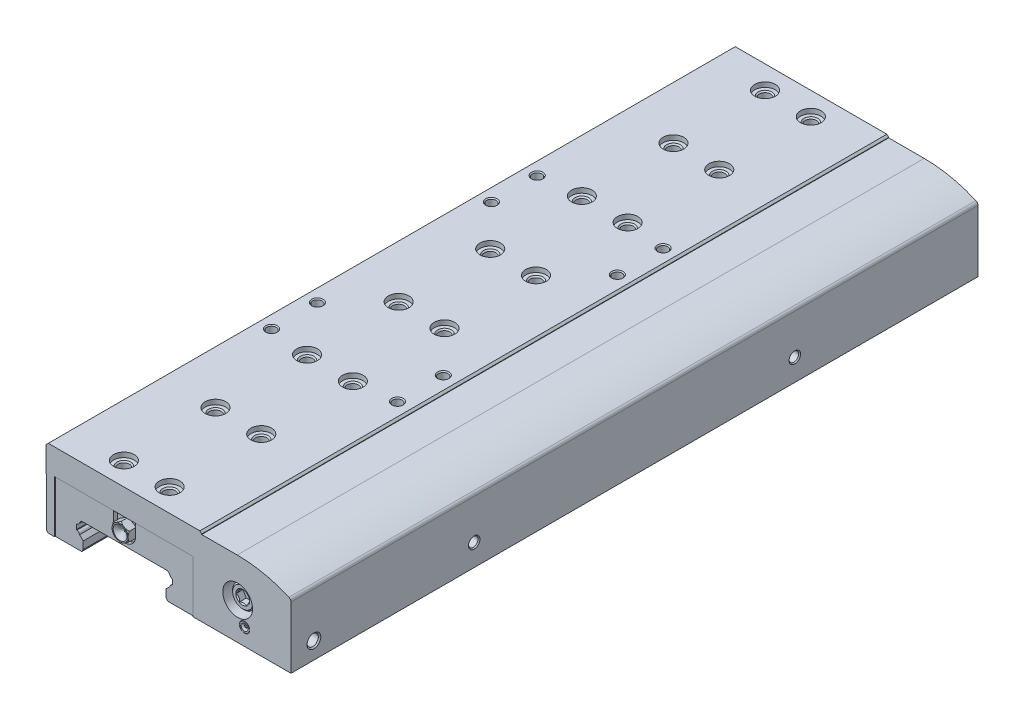
from build123d import *

# Parameters (mm, degrees)
BOSS_EXTRUDE1_DEPTH      = 300
SKETCH2_W                = 115
SKETCH2_H                = 45
CUT_EXTRUDE1_DEPTH       = 300
BOSS_EXTRUDE2_DEPTH      = 150
BOSS_EXTRUDE2_DEPTH_BACK = 150
BOSS_EXTRUDE3_DEPTH      = 150
BOSS_EXTRUDE3_DEPTH_BACK = 150
SKETCH4_W                = 60.6
SKETCH4_H                = 22.8
CUT_EXTRUDE2_DEPTH       = 3
CUT_EXTRUDE3_DEPTH       = 3
SKETCH9_W                = 1
SKETCH9_H                = 2.25
SKETCH40_W               = 2.1
SKETCH40_H               = 3.5
SKETCH41_W               = 2.1
SKETCH41_H               = 3.5
CUT_EXTRUDE4_DEPTH       = 170
CUT_EXTRUDE4_DEPTH_BACK  = 170
SKETCH43_W               = 60.6
SKETCH43_H               = 22.8
CUT_EXTRUDE5_DEPTH       = 0.35
CUT_EXTRUDE6_DEPTH       = 0.35
CUT_EXTRUDE6_DEPTH_BACK  = 0.35
SKETCH44_W               = 60.6
SKETCH44_H               = 22.8
CUT_EXTRUDE7_DEPTH       = 1.95
CUT_EXTRUDE8_START       = 1.95
CUT_EXTRUDE8_DEPTH       = 1.95
CUT_EXTRUDE9_DEPTH       = 1.95
CUT_EXTRUDE9_DEPTH_BACK  = 1.95
SKETCH49_R               = 4.7
CUT_EXTRUDE10_DEPTH      = 1.95
CUT_EXTRUDE10_DEPTH_BACK = 1.95
SKETCH50_R               = 4.7


with BuildPart() as part:
    # Sketch1 → Boss-Extrude1 (new body)
    with BuildSketch(Plane.XY):
        with BuildLine():
            Line((0, 34), (0, 22))
            Line((0, 22), (0.2, 22))
            Line((0.2, 22), (0.2, 0))
            Line((0.2, 0), (3.7, 0))
            Line((3.7, 0), (3.7, 22.8))
            Line((3.7, 22.8), (64.3, 22.8))
            Line((64.3, 22.8), (64.3, 0))
            Line((64.3, 0), (107, 0))
            Line((107, 0), (107, 27.930241671))
            ThreePointArc((107, 27.930241671), (95.52032081, 31.718146843), (83.5, 33))
            Line((83.5, 33), (68, 33))
            Line((68, 33), (68, 34))
            Line((68, 34), (0, 34))
        make_face()
    extrude(amount=-BOSS_EXTRUDE1_DEPTH)

    # Sketch2 → Cut-Extrude1 (cut)
    with BuildSketch(Plane.XY):
        with Locations((55.5, 20.5)):
            Rectangle(SKETCH2_W, SKETCH2_H)
        with BuildLine():
            Line((0, 33), (0, 22))
            Line((0, 22), (0.2, 22))
            Line((0.2, 22), (0.2, 1.2))
            ThreePointArc((0.2, 1.2), (0.551471863, 0.351471863), (1.4, 0))
            Line((1.4, 0), (107, 0))
            Line((107, 0), (107, 26.953410092))
            ThreePointArc((107, 26.953410092), (106.753373869, 27.777457387), (106.094594741, 28.330529221))
            ThreePointArc((106.094594741, 28.330529221), (95.036026925, 31.82042711), (83.5, 33))
            Line((83.5, 33), (68, 33))
            Line((68, 33), (68, 33.2))
            Line((68, 33.2), (67.2, 34))
            Line((67.2, 34), (1, 34))
            Line((1, 34), (0, 33))
        make_face(mode=Mode.SUBTRACT)
    extrude(amount=-CUT_EXTRUDE1_DEPTH, mode=Mode.SUBTRACT)

    # Sketch3 → Boss-Extrude2 (add, two sides: drawn at the far end of the back side and taken through both)
    with BuildSketch(Plane.XY.offset(-150).offset(-BOSS_EXTRUDE2_DEPTH_BACK)):
        Polygon((3.7, 0), (13, 0), (13, 11.5), (55, 11.5), (55, 0), (64.3, 0), (64.3, 22.8), (3.7, 22.8), align=None)
    extrude(amount=BOSS_EXTRUDE2_DEPTH + BOSS_EXTRUDE2_DEPTH_BACK)

    # Sketch4 → Boss-Extrude3 (add, two sides: drawn at the far end of the back side and taken through both)
    with BuildSketch(Plane.XY.offset(-150).offset(-BOSS_EXTRUDE3_DEPTH_BACK)):
        with Locations((34, 11.4)):
            Rectangle(SKETCH4_W, SKETCH4_H)
    extrude(amount=BOSS_EXTRUDE3_DEPTH + BOSS_EXTRUDE3_DEPTH_BACK)

    # Sketch5 → Cut-Revolve1 (revolve, cut)
    with BuildSketch(Plane(origin=(83.7, 0, 0), x_dir=(0, 0, -1), z_dir=(1, 0, 0))):
        Polygon((299.95, 16), (299.95, 19.55), (299.25, 20.25), (300, 21), (300, 16), align=None)
    revolve(axis=Axis((83.7, 16, -300), (0, 0, 1)), mode=Mode.SUBTRACT)

    # Sketch6 → Cut-Extrude2 (cut)
    with BuildSketch(Plane(origin=(0, 0, -299.95), x_dir=(-1, 0, 0), z_dir=(0, 0, -1))):
        Polygon((-84.854700538, 14), (-82.545299462, 14), (-81.390598923, 16), (-82.545299462, 18), (-84.854700538, 18), (-86.009401077, 16), align=None)
    extrude(amount=-CUT_EXTRUDE2_DEPTH, mode=Mode.SUBTRACT)

    # Sketch7 → Cut-Revolve2 (revolve, cut)
    with BuildSketch(Plane(origin=(83.7, 0, 0), x_dir=(0, 0, -1), z_dir=(1, 0, 0))):
        Polygon((0, 16), (0, 22.5), (8.2, 22.5), (8.2, 21), (2.8, 21), (2.2, 20.4), (2.2, 19), (5.2, 16), align=None)
    revolve(axis=Axis((83.7, 16, -5.2), (0, 0, 1)), mode=Mode.SUBTRACT)

    # Sketch8 → Cut-Extrude3 (cut)
    with BuildSketch(Plane.XY.offset(-2.2)):
        Polygon((82.256624327, 13.5), (85.143375673, 13.5), (86.586751346, 16), (85.143375673, 18.5), (82.256624327, 18.5), (80.813248654, 16), align=None)
    extrude(amount=-CUT_EXTRUDE3_DEPTH, mode=Mode.SUBTRACT)

    # Sketch9 → Cut-Revolve3 (revolve, cut)
    with BuildSketch(Plane(origin=(86.7, 0, 0), x_dir=(0, 0, -1), z_dir=(1, 0, 0))):
        with Locations((0.5, 8.425)):
            Rectangle(SKETCH9_W, SKETCH9_H)
    revolve(axis=Axis((86.7, 7.3, -1), (0, 0, 1)), mode=Mode.SUBTRACT)

    # Sketch10 → Revolve1 (revolve)
    with BuildSketch(Plane(origin=(86.7, 0, 0), x_dir=(0, 0, -1), z_dir=(1, 0, 0))):
        with BuildLine():
            Line((0.8, 7.85), (0.548482756, 7.85))
            Line((0.548482756, 7.85), (0, 8.8))
            Line((0, 8.8), (0, 9.4))
            Line((0, 9.4), (1, 9.4))
            Line((1, 9.4), (1, 7.3))
            Line((1, 7.3), (0.533012702, 7.3))
            ThreePointArc((0.533012702, 7.3), (0.603287011, 7.605688656), (0.8, 7.85))
        make_face()
    revolve(axis=Axis((86.7, 7.3, -1), (0, 0, 1)))

    # Sketch11 → Cut-Revolve4 (revolve, cut)
    with BuildSketch(Plane(origin=(0, 9.5, 0), x_dir=(1, 0, 0), z_dir=(0, 1, 0))):
        Polygon((107, 80), (107, 77.5), (106.567, 77.933), (97, 77.933), (95.806616994, 80), align=None)
    revolve(axis=Axis((95.806616994, 9.5, -80), (1, 0, 0)), mode=Mode.SUBTRACT)

    # Sketch12 → Cut-Revolve5 (revolve, cut)
    with BuildSketch(Plane(origin=(0, 9.5, 0), x_dir=(1, 0, 0), z_dir=(0, 1, 0))):
        Polygon((107, 220), (107, 217.5), (106.567, 217.933), (97, 217.933), (95.806616994, 220), align=None)
    revolve(axis=Axis((95.806616994, 9.5, -220), (1, 0, 0)), mode=Mode.SUBTRACT)

    # Sketch13 → Cut-Revolve6 (revolve, cut)
    with BuildSketch(Plane.XY.offset(-10)):
        Polygon((99, 7.3), (99, 9.7585), (106.4585, 9.7585), (107, 10.3), (107, 7.3), align=None)
    revolve(axis=Axis((107, 7.3, -10), (-1, 0, 0)), mode=Mode.SUBTRACT)

    # Sketch14 → Cut-Revolve7 (revolve, cut)
    with BuildSketch(Plane(origin=(6.5, 0, 0), x_dir=(0, 0, -1), z_dir=(1, 0, 0))):
        Polygon((92, 34), (94.5, 34), (94.067, 33.567), (94.067, 26.5), (92, 26.5), align=None)
    revolve(axis=Axis((6.5, 26.5, -92), (0, 1, 0)), mode=Mode.SUBTRACT)

    # Sketch15 → Cut-Revolve8 (revolve, cut)
    with BuildSketch(Plane(origin=(61.5, 0, 0), x_dir=(0, 0, -1), z_dir=(1, 0, 0))):
        Polygon((92, 34), (94.5, 34), (94.067, 33.567), (94.067, 26.5), (92, 26.5), align=None)
    revolve(axis=Axis((61.5, 26.5, -92), (0, 1, 0)), mode=Mode.SUBTRACT)

    # Sketch16 → Cut-Revolve9 (revolve, cut)
    with BuildSketch(Plane(origin=(61.5, 0, 0), x_dir=(0, 0, -1), z_dir=(1, 0, 0))):
        Polygon((112, 34), (114.5, 34), (114.067, 33.567), (114.067, 26.5), (112, 26.5), align=None)
    revolve(axis=Axis((61.5, 26.5, -112), (0, 1, 0)), mode=Mode.SUBTRACT)

    # Sketch17 → Cut-Revolve10 (revolve, cut)
    with BuildSketch(Plane(origin=(6.5, 0, 0), x_dir=(0, 0, -1), z_dir=(1, 0, 0))):
        Polygon((112, 34), (114.5, 34), (114.067, 33.567), (114.067, 26.5), (112, 26.5), align=None)
    revolve(axis=Axis((6.5, 26.5, -112), (0, 1, 0)), mode=Mode.SUBTRACT)

    # Sketch18 → Cut-Revolve11 (revolve, cut)
    with BuildSketch(Plane(origin=(61.5, 0, 0), x_dir=(0, 0, -1), z_dir=(1, 0, 0))):
        Polygon((188, 34), (190.5, 34), (190.067, 33.567), (190.067, 26.5), (188, 26.5), align=None)
    revolve(axis=Axis((61.5, 26.5, -188), (0, 1, 0)), mode=Mode.SUBTRACT)

    # Sketch19 → Cut-Revolve12 (revolve, cut)
    with BuildSketch(Plane(origin=(6.5, 0, 0), x_dir=(0, 0, -1), z_dir=(1, 0, 0))):
        Polygon((188, 34), (190.5, 34), (190.067, 33.567), (190.067, 26.5), (188, 26.5), align=None)
    revolve(axis=Axis((6.5, 26.5, -188), (0, 1, 0)), mode=Mode.SUBTRACT)

    # Sketch20 → Cut-Revolve13 (revolve, cut)
    with BuildSketch(Plane(origin=(61.5, 0, 0), x_dir=(0, 0, -1), z_dir=(1, 0, 0))):
        Polygon((208, 34), (210.5, 34), (210.067, 33.567), (210.067, 26.5), (208, 26.5), align=None)
    revolve(axis=Axis((61.5, 26.5, -208), (0, 1, 0)), mode=Mode.SUBTRACT)

    # Sketch21 → Cut-Revolve14 (revolve, cut)
    with BuildSketch(Plane(origin=(6.5, 0, 0), x_dir=(0, 0, -1), z_dir=(1, 0, 0))):
        Polygon((208, 34), (210.5, 34), (210.067, 33.567), (210.067, 26.5), (208, 26.5), align=None)
    revolve(axis=Axis((6.5, 26.5, -208), (0, 1, 0)), mode=Mode.SUBTRACT)

    # Sketch22 → Cut-Revolve15 (revolve, cut)
    with BuildSketch(Plane(origin=(24, 0, 0), x_dir=(0, 0, -1), z_dir=(1, 0, 0))):
        Polygon((10, 25.4), (7.5415, 25.4), (7.5415, 31.3585), (7, 31.9), (5.5, 31.9), (5.5, 34), (10, 34), align=None)
    revolve(axis=Axis((24, 31.9, -10), (0, -1, 0)), mode=Mode.SUBTRACT)

    # Sketch23 → Cut-Revolve16 (revolve, cut)
    with BuildSketch(Plane(origin=(24, 0, 0), x_dir=(0, 0, -1), z_dir=(1, 0, 0))):
        Polygon((50, 25.4), (47.5415, 25.4), (47.5415, 31.3585), (47, 31.9), (45.5, 31.9), (45.5, 34), (50, 34), align=None)
    revolve(axis=Axis((24, 31.9, -50), (0, -1, 0)), mode=Mode.SUBTRACT)

    # Sketch24 → Cut-Revolve17 (revolve, cut)
    with BuildSketch(Plane(origin=(24, 0, 0), x_dir=(0, 0, -1), z_dir=(1, 0, 0))):
        Polygon((90, 25.4), (87.5415, 25.4), (87.5415, 31.3585), (87, 31.9), (85.5, 31.9), (85.5, 34), (90, 34), align=None)
    revolve(axis=Axis((24, 31.9, -90), (0, -1, 0)), mode=Mode.SUBTRACT)

    # Sketch25 → Cut-Revolve18 (revolve, cut)
    with BuildSketch(Plane(origin=(24, 0, 0), x_dir=(0, 0, -1), z_dir=(1, 0, 0))):
        Polygon((130, 25.4), (127.5415, 25.4), (127.5415, 31.3585), (127, 31.9), (125.5, 31.9), (125.5, 34), (130, 34), align=None)
    revolve(axis=Axis((24, 31.9, -130), (0, -1, 0)), mode=Mode.SUBTRACT)

    # Sketch26 → Cut-Revolve19 (revolve, cut)
    with BuildSketch(Plane(origin=(24, 0, 0), x_dir=(0, 0, -1), z_dir=(1, 0, 0))):
        Polygon((170, 25.4), (167.5415, 25.4), (167.5415, 31.3585), (167, 31.9), (165.5, 31.9), (165.5, 34), (170, 34), align=None)
    revolve(axis=Axis((24, 31.9, -170), (0, -1, 0)), mode=Mode.SUBTRACT)

    # Sketch27 → Cut-Revolve20 (revolve, cut)
    with BuildSketch(Plane(origin=(24, 0, 0), x_dir=(0, 0, -1), z_dir=(1, 0, 0))):
        Polygon((210, 25.4), (207.5415, 25.4), (207.5415, 31.3585), (207, 31.9), (205.5, 31.9), (205.5, 34), (210, 34), align=None)
    revolve(axis=Axis((24, 31.9, -210), (0, -1, 0)), mode=Mode.SUBTRACT)

    # Sketch28 → Cut-Revolve21 (revolve, cut)
    with BuildSketch(Plane(origin=(24, 0, 0), x_dir=(0, 0, -1), z_dir=(1, 0, 0))):
        Polygon((250, 25.4), (247.5415, 25.4), (247.5415, 31.3585), (247, 31.9), (245.5, 31.9), (245.5, 34), (250, 34), align=None)
    revolve(axis=Axis((24, 31.9, -250), (0, -1, 0)), mode=Mode.SUBTRACT)

    # Sketch29 → Cut-Revolve22 (revolve, cut)
    with BuildSketch(Plane(origin=(24, 0, 0), x_dir=(0, 0, -1), z_dir=(1, 0, 0))):
        Polygon((290, 25.4), (287.5415, 25.4), (287.5415, 31.3585), (287, 31.9), (285.5, 31.9), (285.5, 34), (290, 34), align=None)
    revolve(axis=Axis((24, 31.9, -290), (0, -1, 0)), mode=Mode.SUBTRACT)

    # Sketch30 → Cut-Revolve23 (revolve, cut)
    with BuildSketch(Plane(origin=(44, 0, 0), x_dir=(0, 0, -1), z_dir=(1, 0, 0))):
        Polygon((10, 25.4), (7.5415, 25.4), (7.5415, 31.3585), (7, 31.9), (5.5, 31.9), (5.5, 34), (10, 34), align=None)
    revolve(axis=Axis((44, 31.9, -10), (0, -1, 0)), mode=Mode.SUBTRACT)

    # Sketch31 → Cut-Revolve24 (revolve, cut)
    with BuildSketch(Plane(origin=(44, 0, 0), x_dir=(0, 0, -1), z_dir=(1, 0, 0))):
        Polygon((50, 25.4), (47.5415, 25.4), (47.5415, 31.3585), (47, 31.9), (45.5, 31.9), (45.5, 34), (50, 34), align=None)
    revolve(axis=Axis((44, 31.9, -50), (0, -1, 0)), mode=Mode.SUBTRACT)

    # Sketch32 → Cut-Revolve25 (revolve, cut)
    with BuildSketch(Plane(origin=(44, 0, 0), x_dir=(0, 0, -1), z_dir=(1, 0, 0))):
        Polygon((90, 25.4), (87.5415, 25.4), (87.5415, 31.3585), (87, 31.9), (85.5, 31.9), (85.5, 34), (90, 34), align=None)
    revolve(axis=Axis((44, 31.9, -90), (0, -1, 0)), mode=Mode.SUBTRACT)

    # Sketch33 → Cut-Revolve26 (revolve, cut)
    with BuildSketch(Plane(origin=(44, 0, 0), x_dir=(0, 0, -1), z_dir=(1, 0, 0))):
        Polygon((130, 25.4), (127.5415, 25.4), (127.5415, 31.3585), (127, 31.9), (125.5, 31.9), (125.5, 34), (130, 34), align=None)
    revolve(axis=Axis((44, 31.9, -130), (0, -1, 0)), mode=Mode.SUBTRACT)

    # Sketch34 → Cut-Revolve27 (revolve, cut)
    with BuildSketch(Plane(origin=(44, 0, 0), x_dir=(0, 0, -1), z_dir=(1, 0, 0))):
        Polygon((170, 25.4), (167.5415, 25.4), (167.5415, 31.3585), (167, 31.9), (165.5, 31.9), (165.5, 34), (170, 34), align=None)
    revolve(axis=Axis((44, 31.9, -170), (0, -1, 0)), mode=Mode.SUBTRACT)

    # Sketch35 → Cut-Revolve28 (revolve, cut)
    with BuildSketch(Plane(origin=(44, 0, 0), x_dir=(0, 0, -1), z_dir=(1, 0, 0))):
        Polygon((210, 25.4), (207.5415, 25.4), (207.5415, 31.3585), (207, 31.9), (205.5, 31.9), (205.5, 34), (210, 34), align=None)
    revolve(axis=Axis((44, 31.9, -210), (0, -1, 0)), mode=Mode.SUBTRACT)

    # Sketch36 → Cut-Revolve29 (revolve, cut)
    with BuildSketch(Plane(origin=(44, 0, 0), x_dir=(0, 0, -1), z_dir=(1, 0, 0))):
        Polygon((250, 25.4), (247.5415, 25.4), (247.5415, 31.3585), (247, 31.9), (245.5, 31.9), (245.5, 34), (250, 34), align=None)
    revolve(axis=Axis((44, 31.9, -250), (0, -1, 0)), mode=Mode.SUBTRACT)

    # Sketch37 → Cut-Revolve30 (revolve, cut)
    with BuildSketch(Plane(origin=(44, 0, 0), x_dir=(0, 0, -1), z_dir=(1, 0, 0))):
        Polygon((290, 25.4), (287.5415, 25.4), (287.5415, 31.3585), (287, 31.9), (285.5, 31.9), (285.5, 34), (290, 34), align=None)
    revolve(axis=Axis((44, 31.9, -290), (0, -1, 0)), mode=Mode.SUBTRACT)

    # Sketch38 → Cut-Revolve31 (revolve, cut)
    with BuildSketch(Plane(origin=(0, 27, 0), x_dir=(1, 0, 0), z_dir=(0, 1, 0))):
        Polygon((0, 120), (0, 123), (0.5415, 122.4585), (15, 122.4585), (16.419415637, 120), align=None)
    revolve(axis=Axis((16.419415637, 27, -120), (-1, 0, 0)), mode=Mode.SUBTRACT)

    # Sketch39 → Cut-Revolve32 (revolve, cut)
    with BuildSketch(Plane(origin=(0, 27, 0), x_dir=(1, 0, 0), z_dir=(0, 1, 0))):
        Polygon((0, 180), (0, 183), (0.5415, 182.4585), (15, 182.4585), (16.419415637, 180), align=None)
    revolve(axis=Axis((16.419415637, 27, -180), (-1, 0, 0)), mode=Mode.SUBTRACT)

    # Sketch40 → Cut-Revolve33 (revolve, cut)
    with BuildSketch(Plane(origin=(0, 27, 0), x_dir=(1, 0, 0), z_dir=(0, 1, 0))):
        with Locations((1.05, 206.75)):
            Rectangle(SKETCH40_W, SKETCH40_H)
    revolve(axis=Axis((2.1, 27, -205), (-1, 0, 0)), mode=Mode.SUBTRACT)

    # Sketch41 → Cut-Revolve34 (revolve, cut)
    with BuildSketch(Plane(origin=(0, 27, 0), x_dir=(1, 0, 0), z_dir=(0, 1, 0))):
        with Locations((1.05, 96.75)):
            Rectangle(SKETCH41_W, SKETCH41_H)
    revolve(axis=Axis((2.1, 27, -95), (-1, 0, 0)), mode=Mode.SUBTRACT)

    # Sketch42 → Cut-Extrude4 (cut, two sides: drawn at the far end of the back side and taken through both)
    with BuildSketch(Plane.XY.offset(-150).offset(-CUT_EXTRUDE4_DEPTH_BACK)):
        with BuildLine():
            Line((13, -5), (55, -5))
            Line((55, -5), (55, -3.93))
            Line((55, -3.93), (52.1, 1.092947342))
            Line((52.1, 1.092947342), (52.1, 4.34))
            Line((52.1, 4.34), (53.670892773, 5.910892773))
            ThreePointArc((53.670892773, 5.910892773), (54.063837303, 6.651162697), (54.804107227, 7.044107227))
            Line((54.804107227, 7.044107227), (55, 7.24))
            Line((55, 7.24), (55, 9.25))
            Line((55, 9.25), (54.804107227, 9.445892773))
            ThreePointArc((54.804107227, 9.445892773), (54.063837303, 9.838837303), (53.670892773, 10.579107227))
            Line((53.670892773, 10.579107227), (52.75, 11.5))
            Line((52.75, 11.5), (15.25, 11.5))
            Line((15.25, 11.5), (14.329107227, 10.579107227))
            ThreePointArc((14.329107227, 10.579107227), (13.936162697, 9.838837303), (13.195892773, 9.445892773))
            Line((13.195892773, 9.445892773), (13, 9.25))
            Line((13, 9.25), (13, 7.24))
            Line((13, 7.24), (13.195892773, 7.044107227))
            ThreePointArc((13.195892773, 7.044107227), (13.936162697, 6.651162697), (14.329107227, 5.910892773))
            Line((14.329107227, 5.910892773), (15.9, 4.34))
            Line((15.9, 4.34), (15.9, 1.092947342))
            Line((15.9, 1.092947342), (13, -3.93))
            Line((13, -3.93), (13, -5))
        make_face()
    extrude(amount=CUT_EXTRUDE4_DEPTH + CUT_EXTRUDE4_DEPTH_BACK, mode=Mode.SUBTRACT)

    # Sketch43 → Cut-Extrude5 (cut)
    with BuildSketch(Plane.XY):
        with Locations((34, 11.4)):
            Rectangle(SKETCH43_W, SKETCH43_H)
    extrude(amount=-CUT_EXTRUDE5_DEPTH, mode=Mode.SUBTRACT)

    # Sketch44 → Cut-Extrude6 (cut, two sides: drawn at the far end of the back side and taken through both)
    with BuildSketch(Plane.XY.offset(-300).offset(-CUT_EXTRUDE6_DEPTH_BACK)):
        with Locations((34, 11.4)):
            Rectangle(SKETCH44_W, SKETCH44_H)
    extrude(amount=CUT_EXTRUDE6_DEPTH + CUT_EXTRUDE6_DEPTH_BACK, mode=Mode.SUBTRACT)

    # Sketch45 → Cut-Extrude7 (cut)
    with BuildSketch(Plane.XY):
        with BuildLine():
            Line((29.2, 22.8), (29.2, 17.5))
            ThreePointArc((29.2, 17.5), (34, 12.7), (38.8, 17.5))
            Line((38.8, 17.5), (38.8, 22.8))
            Line((38.8, 22.8), (29.2, 22.8))
        make_face()
    extrude(amount=-CUT_EXTRUDE7_DEPTH, mode=Mode.SUBTRACT)

    # Sketch46 → Cut-Extrude8 (cut)
    with BuildSketch(Plane.XY.offset(-300).offset(CUT_EXTRUDE8_START)):
        with BuildLine():
            Line((29.2, 22.8), (29.2, 17.5))
            ThreePointArc((29.2, 17.5), (34, 12.7), (38.8, 17.5))
            Line((38.8, 17.5), (38.8, 22.8))
            Line((38.8, 22.8), (29.2, 22.8))
        make_face()
    extrude(amount=-CUT_EXTRUDE8_DEPTH, mode=Mode.SUBTRACT)

    # Sketch47 → Revolve2 (revolve)
    with BuildSketch(Plane(origin=(34, 0, 0), x_dir=(0, 0, -1), z_dir=(1, 0, 0))):
        Polygon((298.05, 17.5), (298.05, 21.7), (300.95, 21.7), (301.65, 21), (301.65, 20.5), (299.917949192, 17.5), align=None)
    revolve(axis=Axis((34, 17.5, -299.917949192), (0, 0, 1)))

    # Sketch48 → Revolve3 (revolve)
    with BuildSketch(Plane(origin=(34, 0, 0), x_dir=(0, 0, -1), z_dir=(1, 0, 0))):
        Polygon((0.082050808, 17.5), (-1.65, 20.5), (-1.65, 21), (-0.95, 21.7), (1.95, 21.7), (1.95, 17.5), align=None)
    revolve(axis=Axis((34, 17.5, -1.95), (0, 0, 1)))

    # Sketch49 → Cut-Extrude9 (cut, two sides: drawn at the far end of the back side and taken through both)
    with BuildSketch(Plane.XY.offset(-CUT_EXTRUDE9_DEPTH_BACK)):
        with Locations((34, 17.5)):
            Circle(SKETCH49_R)
        Polygon((30.5, 19.520725942), (30.5, 15.479274058), (34, 13.458548116), (37.5, 15.479274058), (37.5, 19.520725942), (34, 21.541451884), align=None, mode=Mode.SUBTRACT)
    extrude(amount=CUT_EXTRUDE9_DEPTH + CUT_EXTRUDE9_DEPTH_BACK, mode=Mode.SUBTRACT)

    # Sketch50 → Cut-Extrude10 (cut, two sides: drawn at the far end of the back side and taken through both)
    with BuildSketch(Plane.XY.offset(-300).offset(-CUT_EXTRUDE10_DEPTH_BACK)):
        with Locations((34, 17.5)):
            Circle(SKETCH50_R)
        Polygon((30.5, 19.520725942), (30.5, 15.479274058), (34, 13.458548116), (37.5, 15.479274058), (37.5, 19.520725942), (34, 21.541451884), align=None, mode=Mode.SUBTRACT)
    extrude(amount=CUT_EXTRUDE10_DEPTH + CUT_EXTRUDE10_DEPTH_BACK, mode=Mode.SUBTRACT)


solid = part.part
